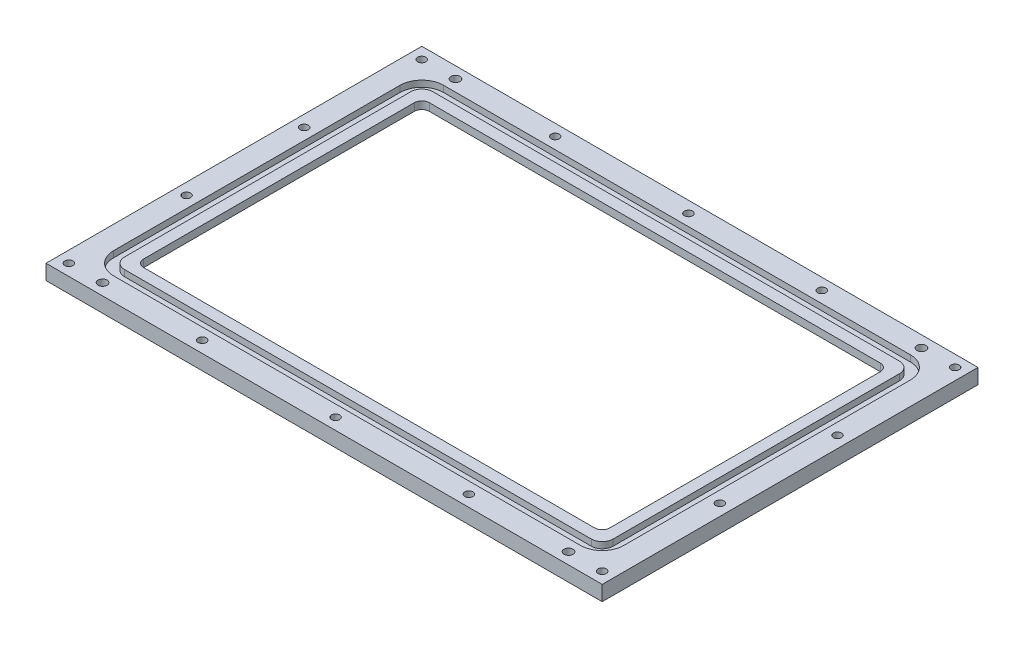
from build123d import *

# Parameters (mm, degrees)
SKETCH1_W             = 203.2
SKETCH1_H             = 127
BOSS_EXTRUDE1_DEPTH   = 6.35
SKETCH2_W             = 196.85
SKETCH2_H             = 120.65
CUT_EXTRUDE1_DEPTH    = 7.35
SKETCH4_W             = 234.95
SKETCH4_H             = 158.75
SKETCH4_W_2           = 203.2
SKETCH4_H_2           = 127
BOSS_EXTRUDE2_DEPTH   = 6.35
SKETCH7_W             = 215.6206
SKETCH7_H             = 139.4206
SKETCH7_W_2           = 206.375
SKETCH7_H_2           = 130.175
CUT_EXTRUDE2_DEPTH    = 2.6416
F_8_32_TAPPED_HOLE1_D = 3.4544
FILLET3_R             = 4.6228
FILLET4_R             = 9.2456
FILLET5_R             = 3.175
F_6_CLEARANCE_HOLE1_D = 3.7973
SKETCH18_W            = 203.2
SKETCH18_H            = 127
CUT_EXTRUDE3_DEPTH    = 3.175
FILLET6_R             = 3.175


with BuildPart() as part:
    # Sketch1 → Boss-Extrude1 (new body)
    with BuildSketch(Plane(origin=(0, 0, 0), x_dir=(1, 0, 0), z_dir=(0, 1, 0))):
        Rectangle(SKETCH1_W, SKETCH1_H)
    extrude(amount=BOSS_EXTRUDE1_DEPTH)

    # Sketch2 → Cut-Extrude1 (cut, through all)
    with BuildSketch(Plane(origin=(0, 6.35, 0), x_dir=(1, 0, 0), z_dir=(0, 1, 0))):
        Rectangle(SKETCH2_W, SKETCH2_H)
    extrude(amount=-CUT_EXTRUDE1_DEPTH, mode=Mode.SUBTRACT)

    # Sketch4 → Boss-Extrude2 (add)
    with BuildSketch(Plane(origin=(0, 6.35, 0), x_dir=(1, 0, 0), z_dir=(0, 1, 0))):
        Rectangle(SKETCH4_W, SKETCH4_H)
        Rectangle(SKETCH4_W_2, SKETCH4_H_2, mode=Mode.SUBTRACT)
    extrude(amount=-BOSS_EXTRUDE2_DEPTH)

    # Sketch7 → Cut-Extrude2 (cut)
    with BuildSketch(Plane(origin=(0, 6.35, 0), x_dir=(1, 0, 0), z_dir=(0, 1, 0))):
        Rectangle(SKETCH7_W, SKETCH7_H)
        Rectangle(SKETCH7_W_2, SKETCH7_H_2, mode=Mode.SUBTRACT)
    extrude(amount=-CUT_EXTRUDE2_DEPTH, mode=Mode.SUBTRACT)

    # #8-32 Tapped Hole1 (through all)
    with Locations(Plane(origin=(0, 6.35, 0), x_dir=(1, 0, 0), z_dir=(0, 1, 0))):
        with Locations((56.321325, 74.54265), (112.64265, 74.54265), (112.64265, 24.84755), (0, 74.54265), (112.64265, -24.84755), (112.64265, -74.54265), (56.321325, -74.54265), (0, -74.54265), (-56.321325, -74.54265), (-112.64265, -74.54265), (-112.64265, -24.84755), (-112.64265, 24.84755), (-112.64265, 74.54265), (-56.321325, 74.54265)):
            Hole(F_8_32_TAPPED_HOLE1_D / 2)

    # Fillet3
    fillet3_edges = [part.edges().sort_by_distance(p)[0] for p in [
        (-103.1875, 5.0292, -65.0875),
        (103.1875, 5.0292, -65.0875),
        (103.1875, 5.0292, 65.0875),
        (-103.1875, 5.0292, 65.0875),
    ]]
    fillet(fillet3_edges, radius=FILLET3_R)

    # Fillet4
    fillet4_edges = [part.edges().sort_by_distance(p)[0] for p in [
        (-107.8103, 5.0292, -69.7103),
        (107.8103, 5.0292, -69.7103),
        (107.8103, 5.0292, 69.7103),
        (-107.8103, 5.0292, 69.7103),
    ]]
    fillet(fillet4_edges, radius=FILLET4_R)

    # Fillet5
    fillet5_edges = [part.edges().sort_by_distance(p)[0] for p in [
        (-98.425, 3.175, -60.325),
        (98.425, 3.175, -60.325),
        (98.425, 3.175, 60.325),
        (-98.425, 3.175, 60.325),
    ]]
    fillet(fillet5_edges, radius=FILLET5_R)

    # #6 Clearance Hole1 (through all)
    with Locations(Plane(origin=(0, 0, 0), x_dir=(-1, 0, 0), z_dir=(0, -1, 0))):
        with Locations((-98.425, 74.54265), (-98.425, -74.54265), (98.425, -74.54265), (98.425, 74.54265)):
            Hole(F_6_CLEARANCE_HOLE1_D / 2)

    # Sketch18 → Cut-Extrude3 (cut)
    with BuildSketch(Plane.XZ):
        Rectangle(SKETCH18_W, SKETCH18_H)
    extrude(amount=-CUT_EXTRUDE3_DEPTH, mode=Mode.SUBTRACT)

    # Fillet6
    fillet6_edges = [part.edges().sort_by_distance(p)[0] for p in [
        (-101.6, 1.5875, -63.5),
        (-101.6, 1.5875, 63.5),
        (101.6, 1.5875, 63.5),
        (101.6, 1.5875, -63.5),
    ]]
    fillet(fillet6_edges, radius=FILLET6_R)


solid = part.part
